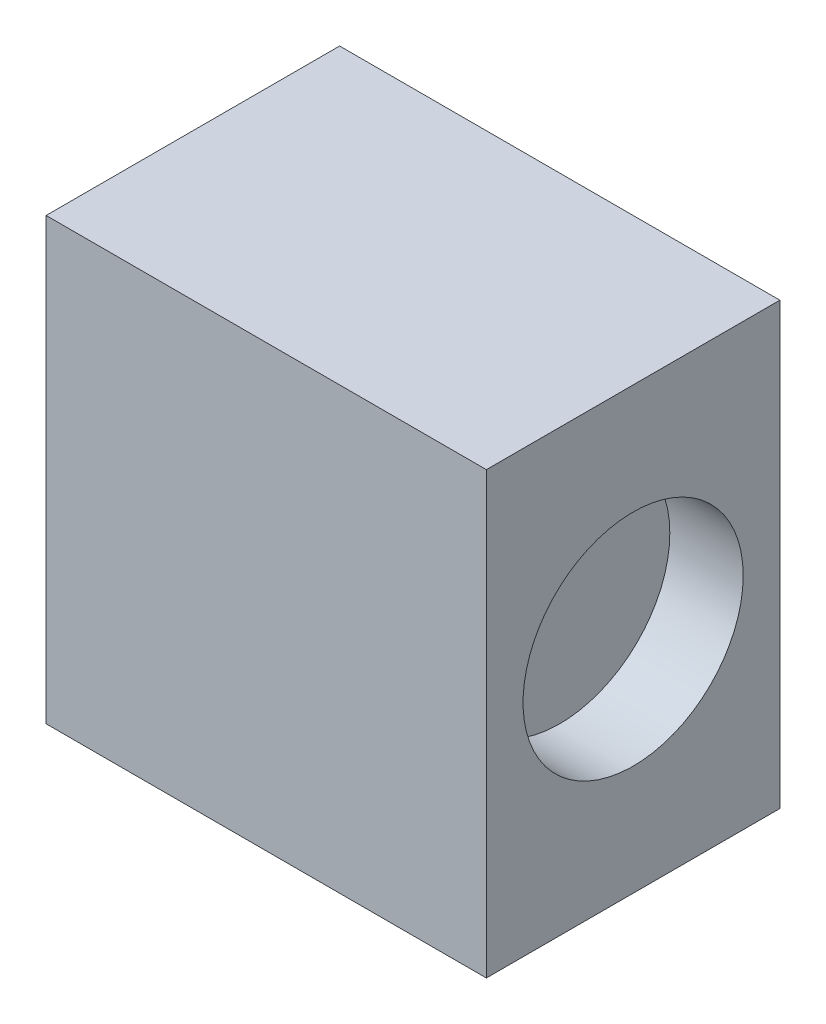
from build123d import *

# Parameters (mm, degrees)
SKETCH1_W           = 6
SKETCH1_H           = 4
BOSS_EXTRUDE1_DEPTH = 6
SKETCH2_R           = 1.5
CUT_EXTRUDE1_DEPTH  = 1


with BuildPart() as part:
    # Sketch1 → Boss-Extrude1 (new body)
    with BuildSketch(Plane(origin=(0, 0, 0), x_dir=(1, 0, 0), z_dir=(0, 1, 0))):
        Rectangle(SKETCH1_W, SKETCH1_H)
    extrude(amount=BOSS_EXTRUDE1_DEPTH)

    # Sketch2 → Cut-Extrude1 (cut)
    with BuildSketch(Plane(origin=(3, 0, 0), x_dir=(0, 0, -1), z_dir=(1, 0, 0))):
        with Locations((0, 3)):
            Circle(SKETCH2_R)
    extrude(amount=-CUT_EXTRUDE1_DEPTH, mode=Mode.SUBTRACT)


solid = part.part
